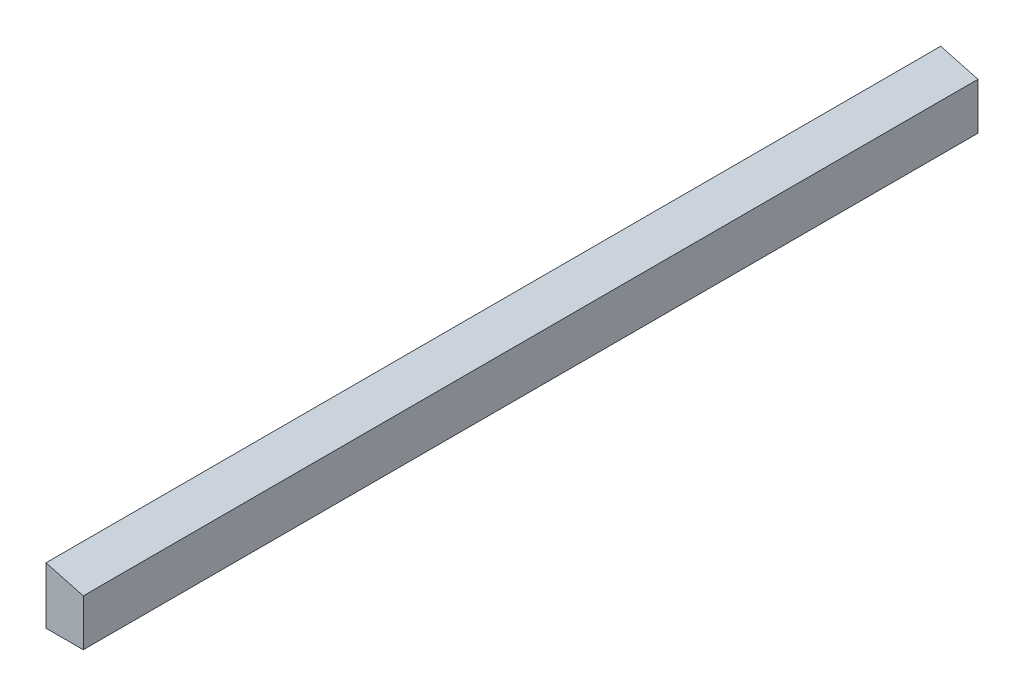
from build123d import *

# Parameters (mm, degrees)
BOSS_EXTRUDE1_DEPTH = 914.4


with BuildPart() as part:
    # Sketch1 → Boss-Extrude1 (new body)
    with BuildSketch(Plane.XY):
        Polygon((-15.082688167, 35.289559184), (23.017311833, 25.080694953), (23.017311833, -22.654190816), (-15.082688167, -22.654190816), align=None)
    extrude(amount=BOSS_EXTRUDE1_DEPTH)


solid = part.part
